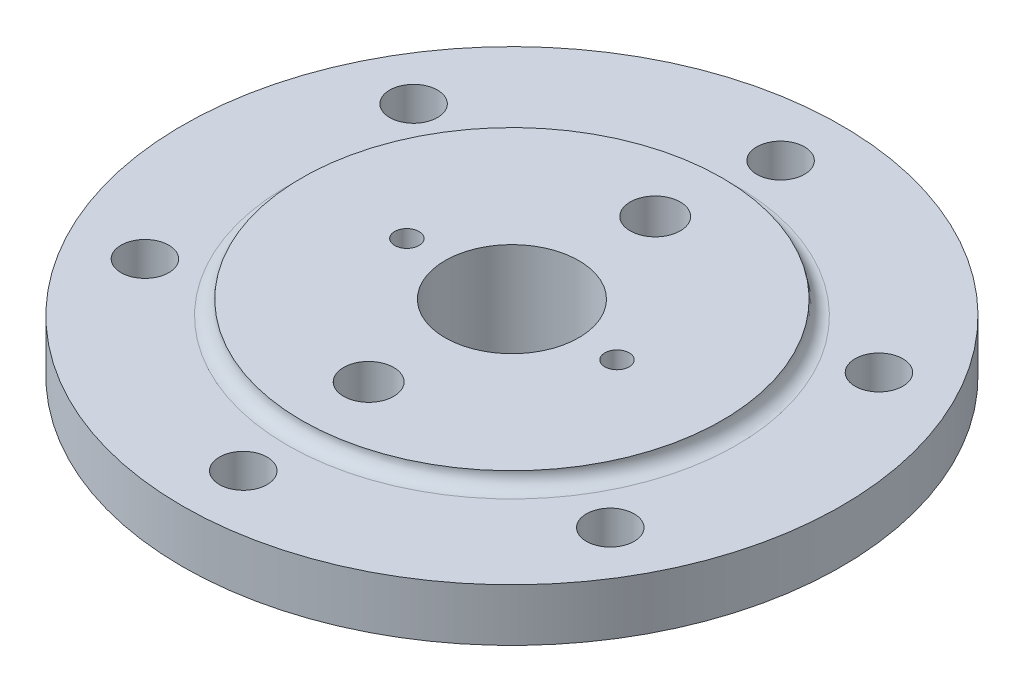
from build123d import *

# Parameters (mm, degrees)
SKETCH2_R              = 10
CUT_EXTRUDE1_DEPTH     = 76
M24_TAPPED_HOLE3_D     = 21
M24_TAPPED_HOLE3_DEPTH = 27
M24_TAPPED_HOLE3_TIP   = 6.3090365
M12_TAPPED_HOLE1_D     = 10.2
M12_TAPPED_HOLE1_DEPTH = 15
M12_TAPPED_HOLE1_TIP   = 3.064389157


with BuildPart() as part:
    # Sketch1 → Revolve1 (revolve)
    with BuildSketch(Plane(origin=(0, 0, 0), x_dir=(0, 0, -1), z_dir=(1, 0, 0))):
        with BuildLine():
            Line((14, 0), (35, 0))
            Line((35, 0), (81, 47))
            Line((81, 47), (81, 53))
            Line((81, 53), (138, 53))
            Line((138, 53), (138, 75))
            Line((138, 75), (94, 75))
            ThreePointArc((94, 75), (89.757359313, 76.757359313), (88, 81))
            Line((88, 81), (28, 81))
            Line((28, 81), (28, 33))
            Line((28, 33), (14, 24.917096231))
            Line((14, 24.917096231), (14, 0))
        make_face()
    revolve(axis=Axis((0, 40.822828071, 0), (0, -1, 0)))

    # Sketch2 → Cut-Extrude1 (cut, through all)
    with BuildSketch(Plane(origin=(0, 75, 0), x_dir=(1, 0, 0), z_dir=(0, 1, 0))):
        with Locations((0, 112.5)):
            Circle(SKETCH2_R)
        with Locations((97.427857926, 56.25)):
            Circle(SKETCH2_R)
        with Locations((97.427857926, -56.25)):
            Circle(SKETCH2_R)
        with Locations((0, -112.5)):
            Circle(SKETCH2_R)
        with Locations((-97.427857926, -56.25)):
            Circle(SKETCH2_R)
        with Locations((-97.427857926, 56.25)):
            Circle(SKETCH2_R)
    extrude(amount=-CUT_EXTRUDE1_DEPTH, mode=Mode.SUBTRACT)

    # M24 Tapped Hole3
    with Locations(Plane(origin=(0, 81, 0), x_dir=(1, 0, 0), z_dir=(0, 1, 0))):
        with Locations((0, 60), (0, -60), (-5.787213998, -5.032102647)):
            Hole(M24_TAPPED_HOLE3_D / 2, depth=M24_TAPPED_HOLE3_DEPTH)
            with Locations((0, 0, -(M24_TAPPED_HOLE3_DEPTH + M24_TAPPED_HOLE3_TIP / 2))):  # 118° drill point
                Cone(0, M24_TAPPED_HOLE3_D / 2, M24_TAPPED_HOLE3_TIP, mode=Mode.SUBTRACT)

    # M12 Tapped Hole1
    with Locations(Plane(origin=(0, 81, 0), x_dir=(1, 0, 0), z_dir=(0, 1, 0))):
        with Locations((-44, 0), (44, 0)):
            Hole(M12_TAPPED_HOLE1_D / 2, depth=M12_TAPPED_HOLE1_DEPTH)
            with Locations((0, 0, -(M12_TAPPED_HOLE1_DEPTH + M12_TAPPED_HOLE1_TIP / 2))):  # 118° drill point
                Cone(0, M12_TAPPED_HOLE1_D / 2, M12_TAPPED_HOLE1_TIP, mode=Mode.SUBTRACT)


solid = part.part
